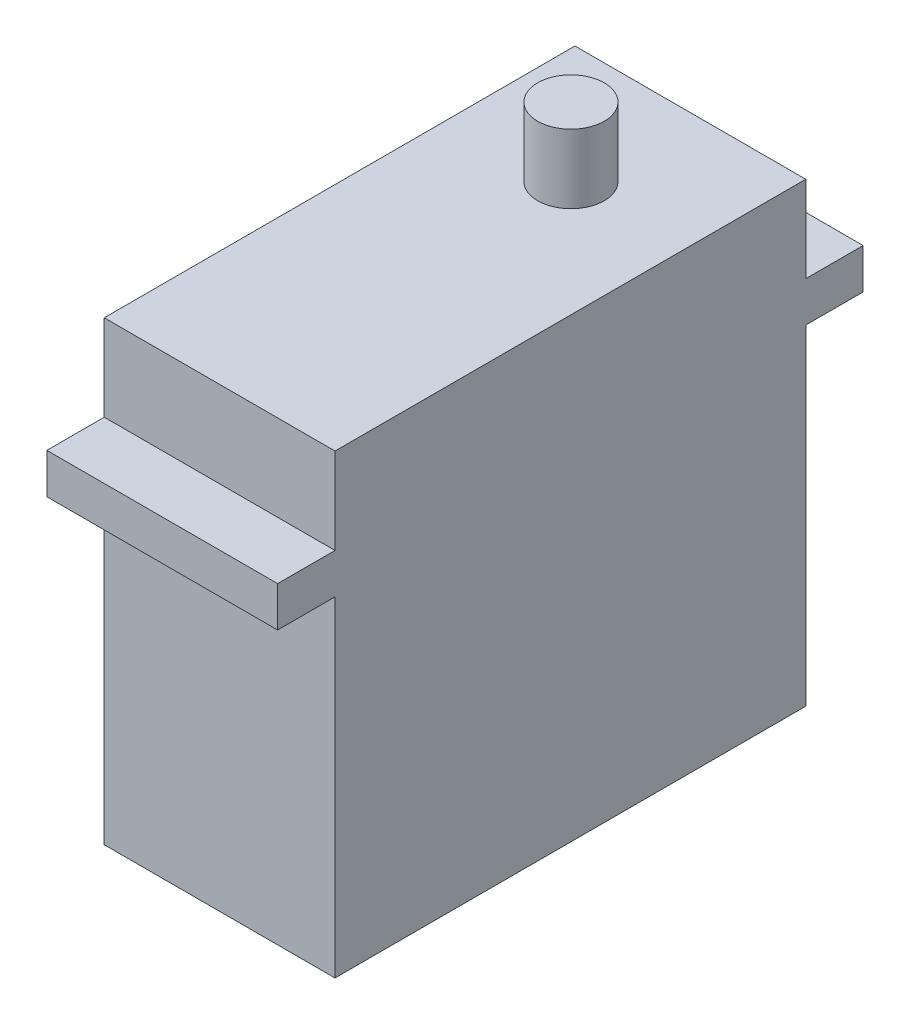
from build123d import *

# Parameters (mm, degrees)
SKETCH2_W           = 41
SKETCH2_H           = 39.75
SKETCH2_W_2         = 5
SKETCH2_H_2         = 3.5
SKETCH2_W_3         = 5.8
SKETCH2_H_3         = 6
BOSS_EXTRUDE1_DEPTH = 20.1
CUT_EXTRUDE1_DEPTH  = 6


with BuildPart() as part:
    # Sketch2 → Boss-Extrude1 (new body)
    with BuildSketch(Plane(origin=(0, 0, 0), x_dir=(0, 0, -1), z_dir=(1, 0, 0))):
        Rectangle(SKETCH2_W, SKETCH2_H)
        with Locations((-23, 10.625)):
            Rectangle(SKETCH2_W_2, SKETCH2_H_2)
        with Locations((10.1, 22.875)):
            Rectangle(SKETCH2_W_3, SKETCH2_H_3)
        with Locations((23, 10.625)):
            Rectangle(SKETCH2_W_2, SKETCH2_H_2)
    extrude(amount=BOSS_EXTRUDE1_DEPTH)

    # Sketch3 → Cut-Extrude1 (cut)
    with BuildSketch(Plane(origin=(0, 19.875, 0), x_dir=(1, 0, 0), z_dir=(0, 1, 0))):
        with BuildLine():
            Line((10.05, 7.2), (12.95, 7.2))
            Line((12.95, 7.2), (12.95, 10.1))
            ThreePointArc((12.95, 10.1), (12.100609665, 8.049390335), (10.05, 7.2))
        make_face()
        with BuildLine():
            ThreePointArc((10.05, 13), (12.100609665, 12.150609665), (12.95, 10.1))
            Line((12.95, 10.1), (12.95, 13))
            Line((12.95, 13), (10.05, 13))
        make_face()
        with BuildLine():
            ThreePointArc((7.15, 10.1), (7.999390335, 12.150609665), (10.05, 13))
            Line((10.05, 13), (7.15, 13))
            Line((7.15, 13), (7.15, 10.1))
        make_face()
        with BuildLine():
            Line((7.15, 7.2), (10.05, 7.2))
            ThreePointArc((10.05, 7.2), (7.999390335, 8.049390335), (7.15, 10.1))
            Line((7.15, 10.1), (7.15, 7.2))
        make_face()
        Polygon((0, 7.2), (7.15, 7.2), (7.15, 10.1), (7.15, 13), (0, 13), align=None)
        Polygon((12.95, 7.2), (20.1, 7.2), (20.1, 13), (12.95, 13), (12.95, 10.1), align=None)
    extrude(amount=CUT_EXTRUDE1_DEPTH, mode=Mode.SUBTRACT)


solid = part.part
